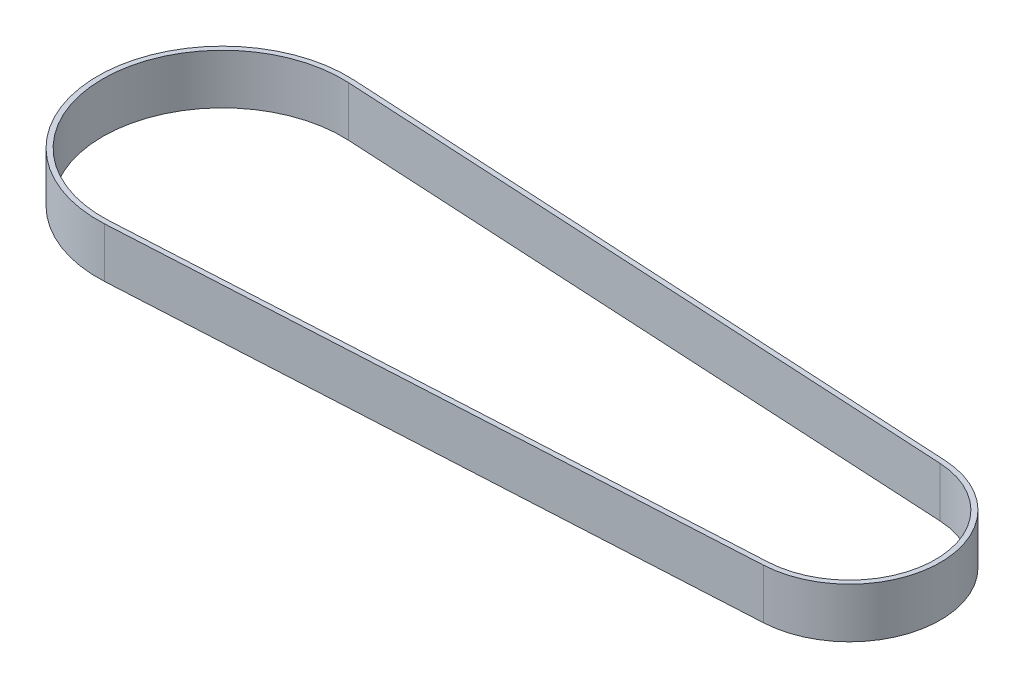
from build123d import *

# Parameters (mm, degrees)
BOSS_EXTRUDE1_DEPTH = 10


with BuildPart() as part:
    # Sketch1 → Boss-Extrude1 (new body)
    with BuildSketch(Plane(origin=(0, 0, 0), x_dir=(1, 0, 0), z_dir=(0, 1, 0))):
        with BuildLine():
            Line((1.353503185, 24.963333694), (126.585350318, 18.173306929))
            ThreePointArc((126.585350318, 18.173306929), (143.8, 0), (126.585350318, -18.173306929))
            Line((126.585350318, -18.173306929), (1.353503185, -24.963333694))
            ThreePointArc((1.353503185, -24.963333694), (-25, 0), (1.353503185, 24.963333694))
        make_face()
        with BuildLine():
            Line((1.299363057, 23.964800346), (126.531210191, 17.174773582))
            ThreePointArc((126.531210191, 17.174773582), (142.8, 0), (126.531210191, -17.174773582))
            Line((126.531210191, -17.174773582), (1.299363057, -23.964800346))
            ThreePointArc((1.299363057, -23.964800346), (-24, 0), (1.299363057, 23.964800346))
        make_face(mode=Mode.SUBTRACT)
    extrude(amount=BOSS_EXTRUDE1_DEPTH)


solid = part.part
